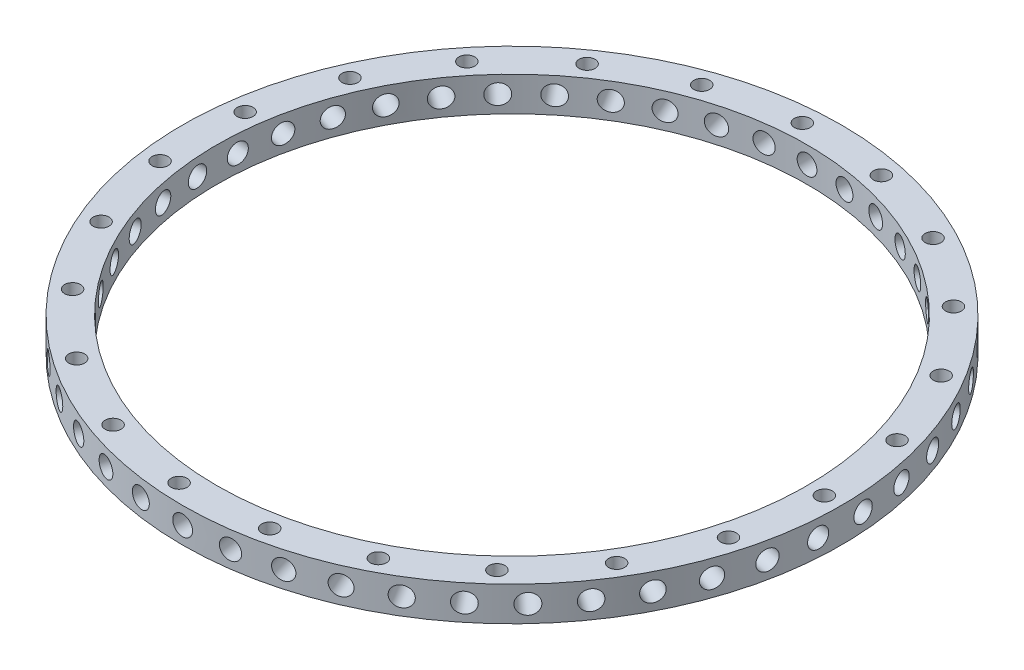
from build123d import *

# Parameters (mm, degrees)
SKETCH1_R           = 60.96
SKETCH1_R_2         = 54.61
BOSS_EXTRUDE1_DEPTH = 6.35
CIRPATTERN1_COUNT   = 46
CIRPATTERN2_COUNT   = 23


with BuildPart() as part:
    # Sketch1 → Boss-Extrude1 (new body)
    with BuildSketch(Plane(origin=(0, 0, 0), x_dir=(1, 0, 0), z_dir=(0, 1, 0))):
        Circle(SKETCH1_R)
        Circle(SKETCH1_R_2, mode=Mode.SUBTRACT)
    extrude(amount=BOSS_EXTRUDE1_DEPTH)

    # Sketch2 → #6 Clearance Hole2 (revolve, cut)
    with BuildSketch(Plane(origin=(0, 3.175, 60.96), x_dir=(0, -1, 0), z_dir=(1, 0, 0))):
        Polygon((0, 0), (0, 13.7988539), (1.8288, 12.7), (1.8288, 0), align=None)
    f_6_clearance_hole2 = revolve(axis=Axis((0, 3.175, 67.31), (0, 0, -1)), mode=Mode.SUBTRACT)

    # CirPattern1: #6 Clearance Hole2 ×46 about axis
    cirpattern1_axis = Axis((0, 6.35, 0), (0, -1, 0))
    for i in range(1, CIRPATTERN1_COUNT):
        add(f_6_clearance_hole2.rotate(cirpattern1_axis, i * 360 / CIRPATTERN1_COUNT), mode=Mode.SUBTRACT)

    # Sketch3 → #4 Clearance Hole1 (revolve, cut)
    with BuildSketch(Plane(origin=(-3.943387856, 6.35, 57.650289828), x_dir=(0, 0, 1), z_dir=(1, 0, 0))):
        Polygon((0, 0), (0, 13.585187864), (1.4732, 12.7), (1.4732, 0), align=None)
    f_4_clearance_hole1 = revolve(axis=Axis((-3.943387856, 12.7, 57.650289828), (0, -1, 0)), mode=Mode.SUBTRACT)

    # CirPattern2: #4 Clearance Hole1 ×23 about axis
    cirpattern2_axis = Axis((0, 0, 0), (0, 1, 0))
    for i in range(1, CIRPATTERN2_COUNT):
        add(f_4_clearance_hole1.rotate(cirpattern2_axis, i * 360 / CIRPATTERN2_COUNT), mode=Mode.SUBTRACT)


solid = part.part
